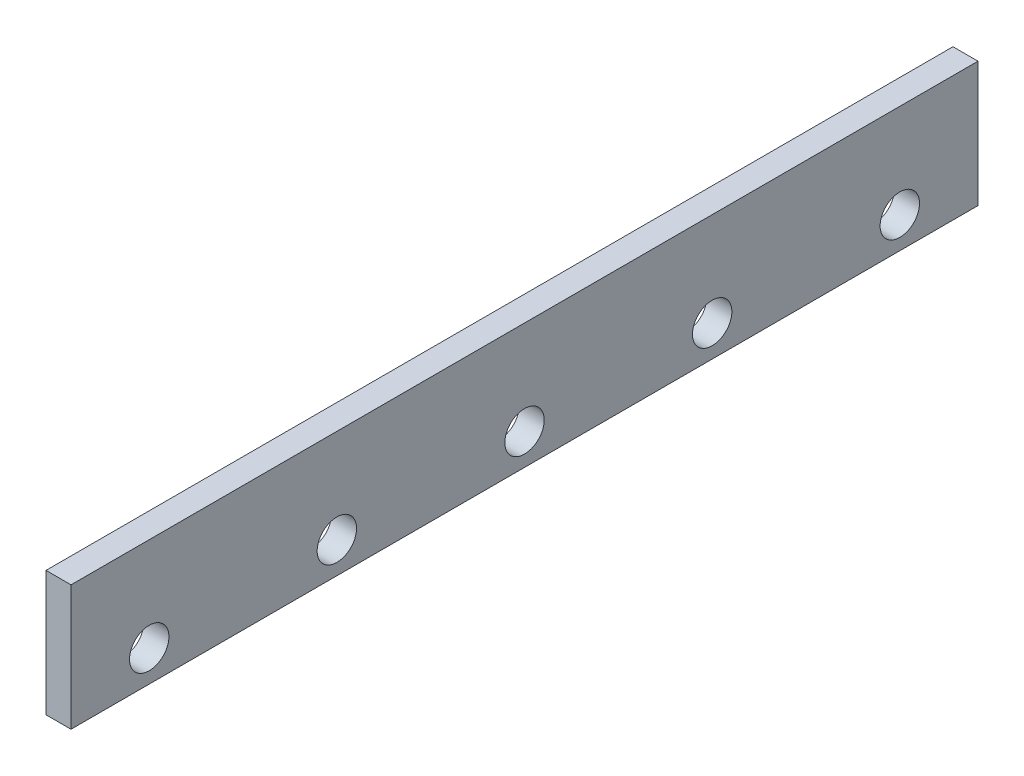
from build123d import *

# Parameters (mm, degrees)
CROQUIS1_W              = 580
CROQUIS1_H              = 80
CROQUIS1_R              = 12.6
SALIENTE_EXTRUIR1_DEPTH = 16


with BuildPart() as part:
    # Croquis1 → Saliente-Extruir1 (new body)
    with BuildSketch(Plane(origin=(0, 0, 0), x_dir=(0, 0, -1), z_dir=(1, 0, 0))):
        with Locations((290, 40)):
            Rectangle(CROQUIS1_W, CROQUIS1_H)
        with Locations((50, 20)):
            Circle(CROQUIS1_R, mode=Mode.SUBTRACT)
        with Locations((170, 20)):
            Circle(CROQUIS1_R, mode=Mode.SUBTRACT)
        with Locations((290, 20)):
            Circle(CROQUIS1_R, mode=Mode.SUBTRACT)
        with Locations((410, 20)):
            Circle(CROQUIS1_R, mode=Mode.SUBTRACT)
        with Locations((530, 20)):
            Circle(CROQUIS1_R, mode=Mode.SUBTRACT)
    extrude(amount=SALIENTE_EXTRUIR1_DEPTH)


solid = part.part
